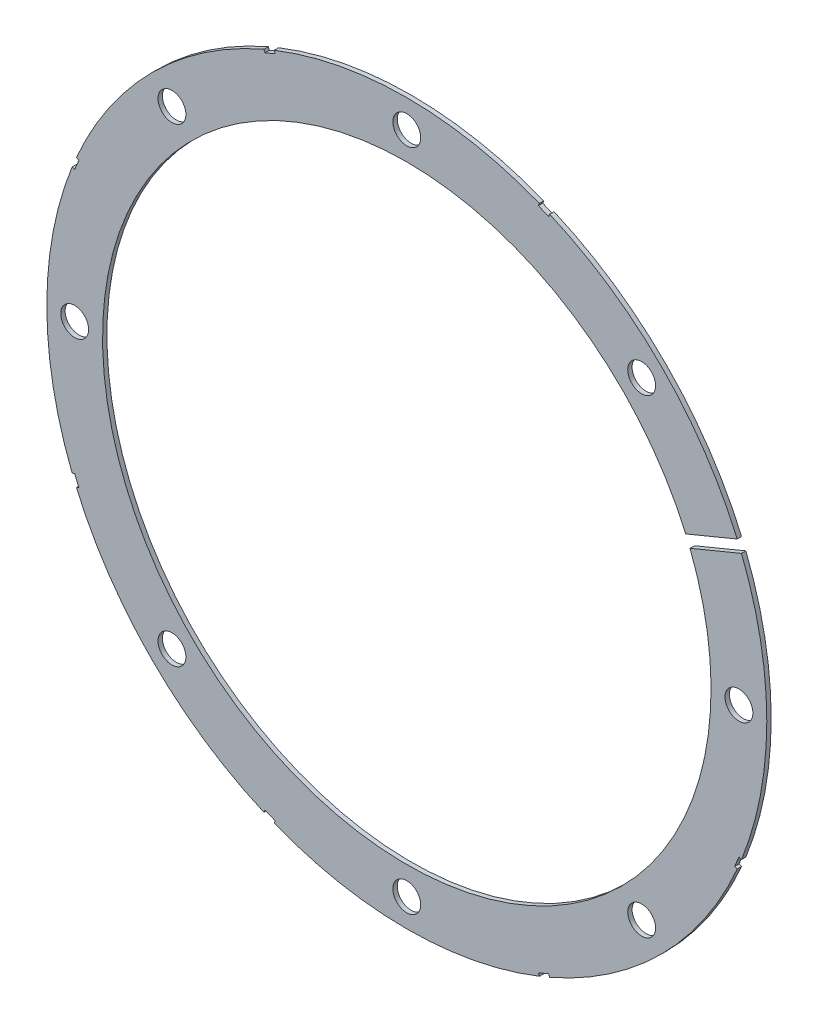
from build123d import *

# Parameters (mm, degrees)
SKETCH4_R           = 82.042
BOSS_EXTRUDE2_DEPTH = 1
SKETCH5_R           = 69.342
CUT_EXTRUDE5_DEPTH  = 2
SKETCH6_R           = 3.175
CUT_EXTRUDE6_DEPTH  = 2
CIRPATTERN1_COUNT   = 8
CUT_EXTRUDE11_DEPTH = 2


with BuildPart() as part:
    # Sketch4 → Boss-Extrude2 (new body)
    with BuildSketch(Plane.XY):
        Circle(SKETCH4_R)
    extrude(amount=BOSS_EXTRUDE2_DEPTH)

    # Sketch5 → Cut-Extrude5 (cut, through all)
    with BuildSketch(Plane.XY.offset(1)):
        Circle(SKETCH5_R)
    extrude(amount=-CUT_EXTRUDE5_DEPTH, mode=Mode.SUBTRACT)

    # Sketch6 → Cut-Extrude6 (cut, through all)
    with BuildSketch(Plane.XY.offset(1)):
        with Locations((75.692, 0)):
            Circle(SKETCH6_R)
    cut_extrude6 = extrude(amount=-CUT_EXTRUDE6_DEPTH, mode=Mode.SUBTRACT)

    # CirPattern1: Cut-Extrude6 ×8 about axis
    cirpattern1_axis = Axis((0, 0, 0), (0, 0, 1))
    for i in range(1, CIRPATTERN1_COUNT):
        add(cut_extrude6.rotate(cirpattern1_axis, i * 360 / CIRPATTERN1_COUNT), mode=Mode.SUBTRACT)

    # Sketch8 → Cut-Extrude11 (cut, through all)
    with BuildSketch(Plane.XY.offset(1)):
        Polygon((78.830897666, 34.027465042), (60.057665565, 26.251337696), (61.029681484, 23.904683683), (79.802913584, 31.680811029), align=None)
        Polygon((32.812445144, 75.89758015), (30.465791131, 76.869596069), (29.979783172, 75.696269062), (32.326437185, 74.724253144), align=None)
        Polygon((-30.465791131, 76.869596069), (-32.812445144, 75.89758015), (-32.326437185, 74.724253144), (-29.979783172, 75.696269062), align=None)
        Polygon((-75.89758015, 32.812445144), (-76.869596069, 30.465791131), (-75.696269062, 29.979783172), (-74.724253144, 32.326437185), align=None)
        Polygon((-76.869596069, -30.465791131), (-75.89758015, -32.812445144), (-74.724253144, -32.326437185), (-75.696269062, -29.979783172), align=None)
        Polygon((-32.812445144, -75.89758015), (-30.465791131, -76.869596069), (-29.979783172, -75.696269062), (-32.326437185, -74.724253144), align=None)
        Polygon((30.465791131, -76.869596069), (32.812445144, -75.89758015), (32.326437185, -74.724253144), (29.979783172, -75.696269062), align=None)
        Polygon((75.89758015, -32.812445144), (76.869596069, -30.465791131), (75.696269062, -29.979783172), (74.724253144, -32.326437185), align=None)
    extrude(amount=-CUT_EXTRUDE11_DEPTH, mode=Mode.SUBTRACT)


solid = part.part
